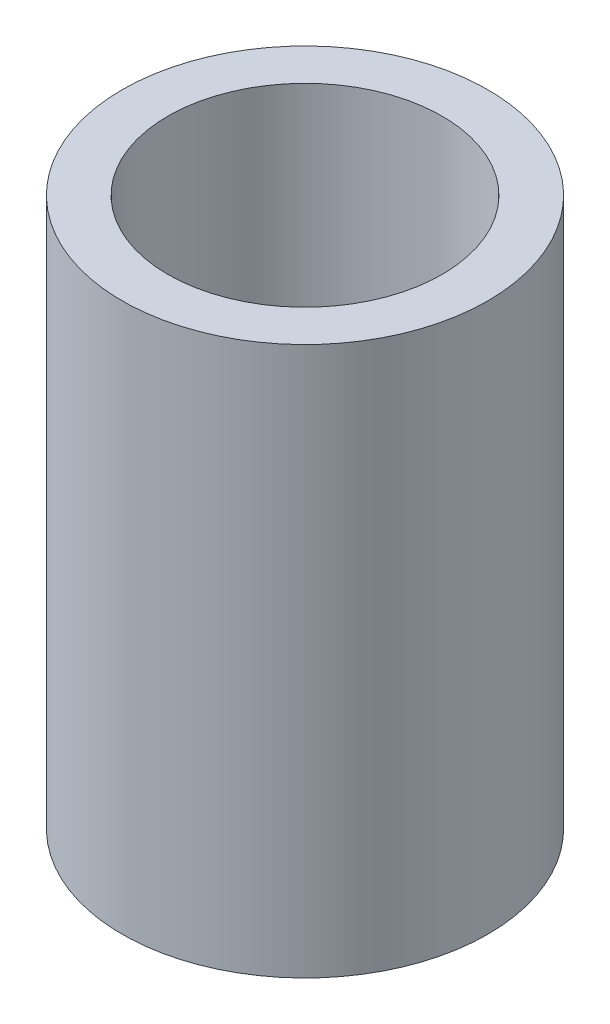
from build123d import *

# Parameters (mm, degrees)
SKETCH3_R           = 4
SKETCH3_R_2         = 3
EXTRUDE_THIN1_DEPTH = 12


with BuildPart() as part:
    # Sketch3 → Extrude-Thin1 (new body)
    with BuildSketch(Plane(origin=(0, 0, 0), x_dir=(1, 0, 0), z_dir=(0, 1, 0))):
        Circle(SKETCH3_R)
        Circle(SKETCH3_R_2, mode=Mode.SUBTRACT)
    extrude(amount=EXTRUDE_THIN1_DEPTH)


solid = part.part
